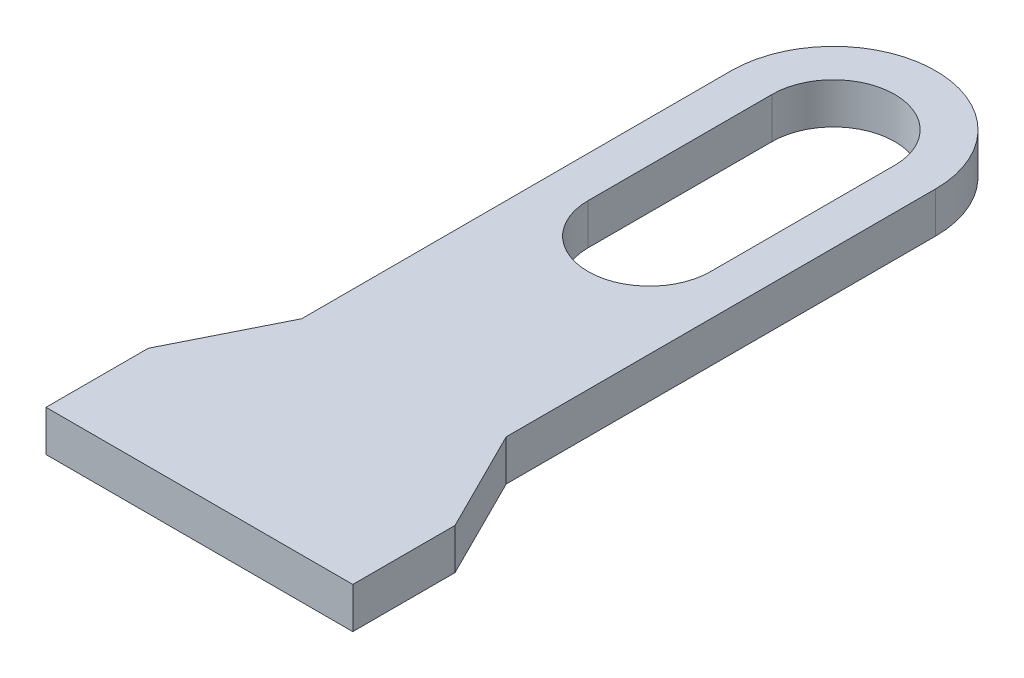
from build123d import *

# Parameters (mm, degrees)
BOSS_EXTRUDE1_DEPTH = 0.4


with BuildPart() as part:
    # Sketch1 → Boss-Extrude1 (new body)
    with BuildSketch(Plane(origin=(0, 0, 0), x_dir=(1, 0, 0), z_dir=(0, 1, 0))):
        with BuildLine():
            Line((1.5, 0), (-1.5, 0))
            Line((-1.5, 0), (-1.5, 1))
            Line((-1.5, 1), (-1, 2))
            Line((-1, 2), (-1, 6.2))
            ThreePointArc((-1, 6.2), (0, 7.2), (1, 6.2))
            Line((1, 6.2), (1, 2))
            Line((1, 2), (1.5, 1))
            Line((1.5, 1), (1.5, 0))
        make_face()
        with BuildLine():
            Line((-0.6, 4.4), (-0.6, 6.2))
            ThreePointArc((-0.6, 6.2), (0, 6.8), (0.6, 6.2))
            Line((0.6, 6.2), (0.6, 4.4))
            ThreePointArc((0.6, 4.4), (0, 3.8), (-0.6, 4.4))
        make_face(mode=Mode.SUBTRACT)
    extrude(amount=BOSS_EXTRUDE1_DEPTH)


solid = part.part
